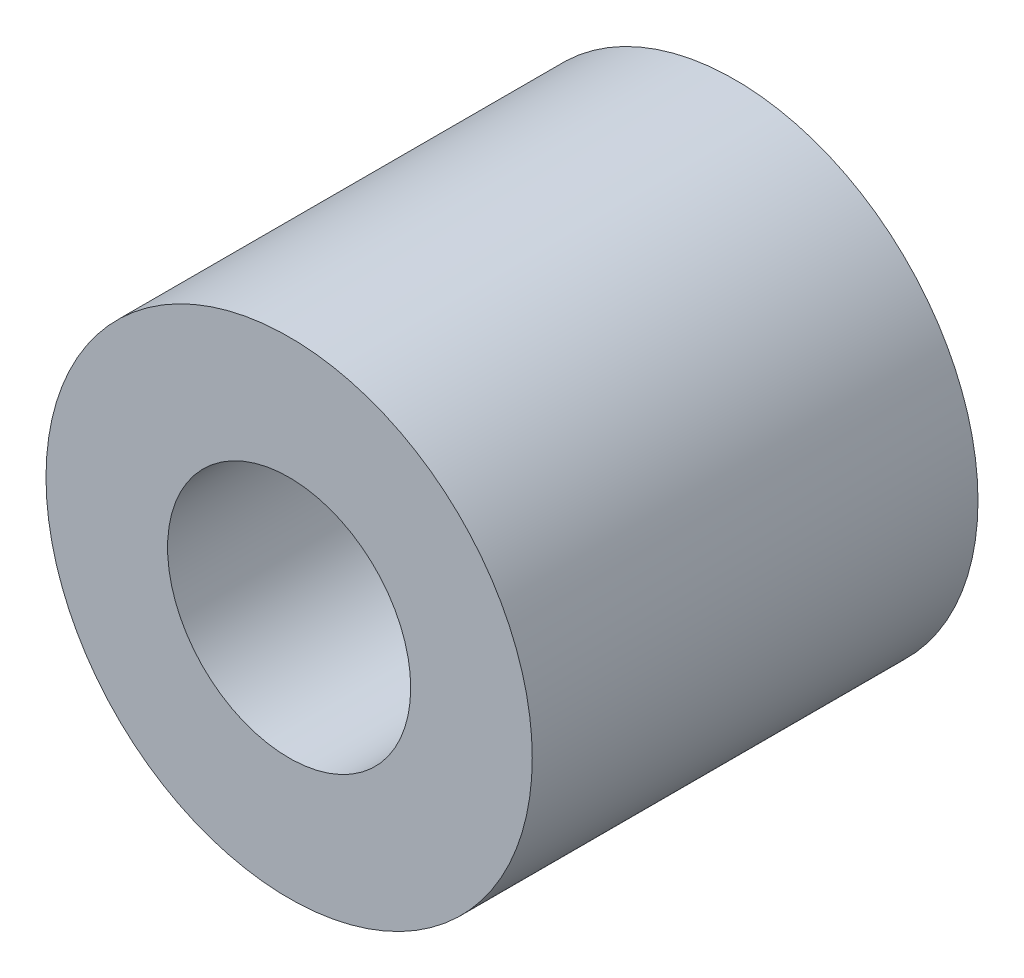
from build123d import *

# Parameters (mm, degrees)
SKETCH_1_5_R    = 3
SKETCH_1_5_R_2  = 1.5
EXTRUDE_4_DEPTH = 5.5


with BuildPart() as part:
    # 草图1<5> → 凸台-拉伸4 (new body)
    with BuildSketch(Plane.XY):
        Circle(SKETCH_1_5_R)
        Circle(SKETCH_1_5_R_2, mode=Mode.SUBTRACT)
    extrude(amount=EXTRUDE_4_DEPTH)


solid = part.part
